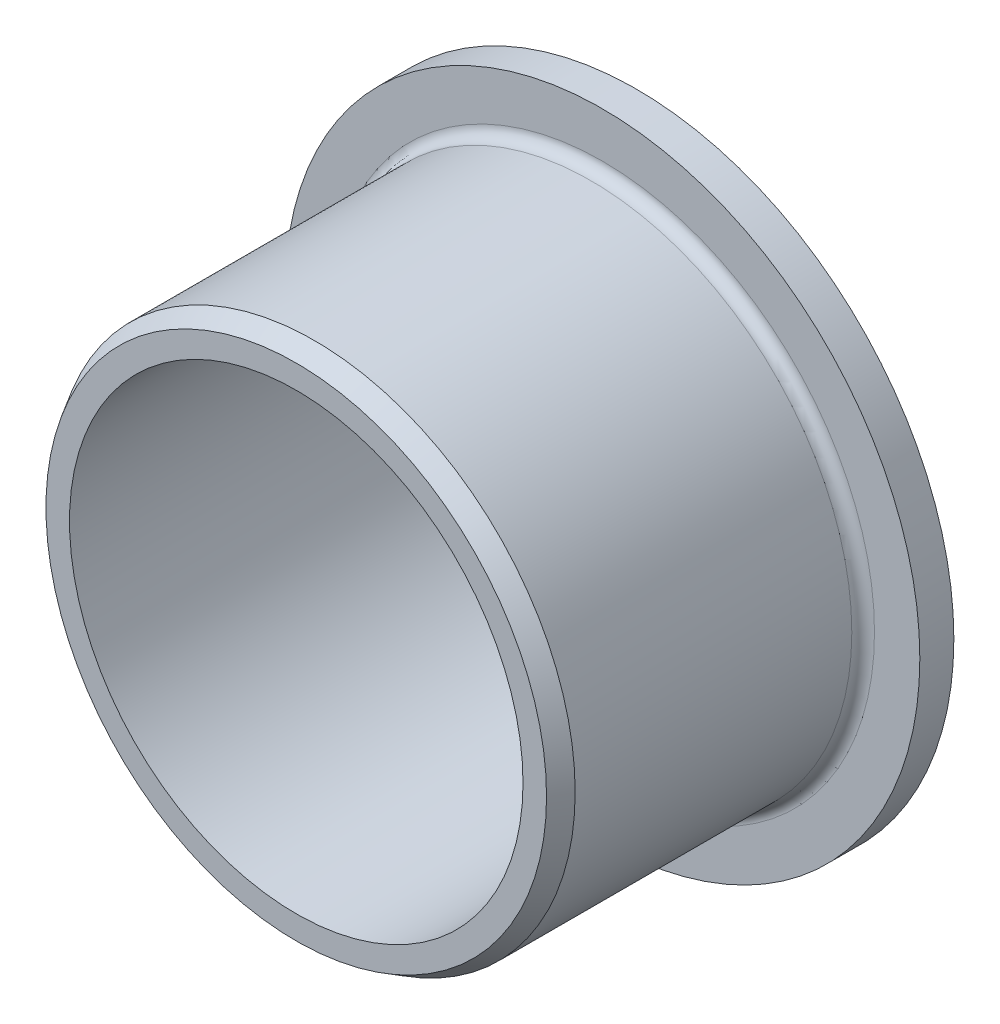
from build123d import *

# Parameters (mm, degrees)
SZKIC1_R                          = 14
SZKIC1_R_2                        = 11.5
WYCI_GNI_CIE_CIENKA_CIANKA1_DEPTH = 1.5
SZKIC2_R                          = 11.5
SZKIC2_R_2                        = 10
DODANIE_WYCI_GNI_CIE1_DEPTH       = 15
ZAOKR_GLENIE1_R                   = 0.5
SFAZOWANIE1_SIZE                  = 0.8
SFAZOWANIE1_SIZE2                 = 0.461880215


with BuildPart() as part:
    # Szkic1 → Wyciągnięcie-cienka ścianka1 (new body)
    with BuildSketch(Plane.XY):
        Circle(SZKIC1_R)
        Circle(SZKIC1_R_2, mode=Mode.SUBTRACT)
    extrude(amount=WYCI_GNI_CIE_CIENKA_CIANKA1_DEPTH)

    # Szkic2 → Dodanie-wyciągnięcie1 (add)
    with BuildSketch(Plane.XY):
        Circle(SZKIC2_R)
        Circle(SZKIC2_R_2, mode=Mode.SUBTRACT)
    extrude(amount=DODANIE_WYCI_GNI_CIE1_DEPTH)

    # Zaokrąglenie1
    zaokr_glenie1_edges = [part.edges().sort_by_distance(p)[0] for p in [
        (-11.5, 0, 1.5),
    ]]
    fillet(zaokr_glenie1_edges, radius=ZAOKR_GLENIE1_R)

    # Sfazowanie1
    sfazowanie1_edges = [part.edges().sort_by_distance(p)[0] for p in [
        (-11.5, 0, 15),
    ]]
    sfazowanie1_side = [part.faces().sort_by_distance(p)[0] for p in [
        (-11.5, 0, 8.5),
    ]]
    chamfer(sfazowanie1_edges, length=SFAZOWANIE1_SIZE, length2=SFAZOWANIE1_SIZE2, reference=sfazowanie1_side[0])


solid = part.part
